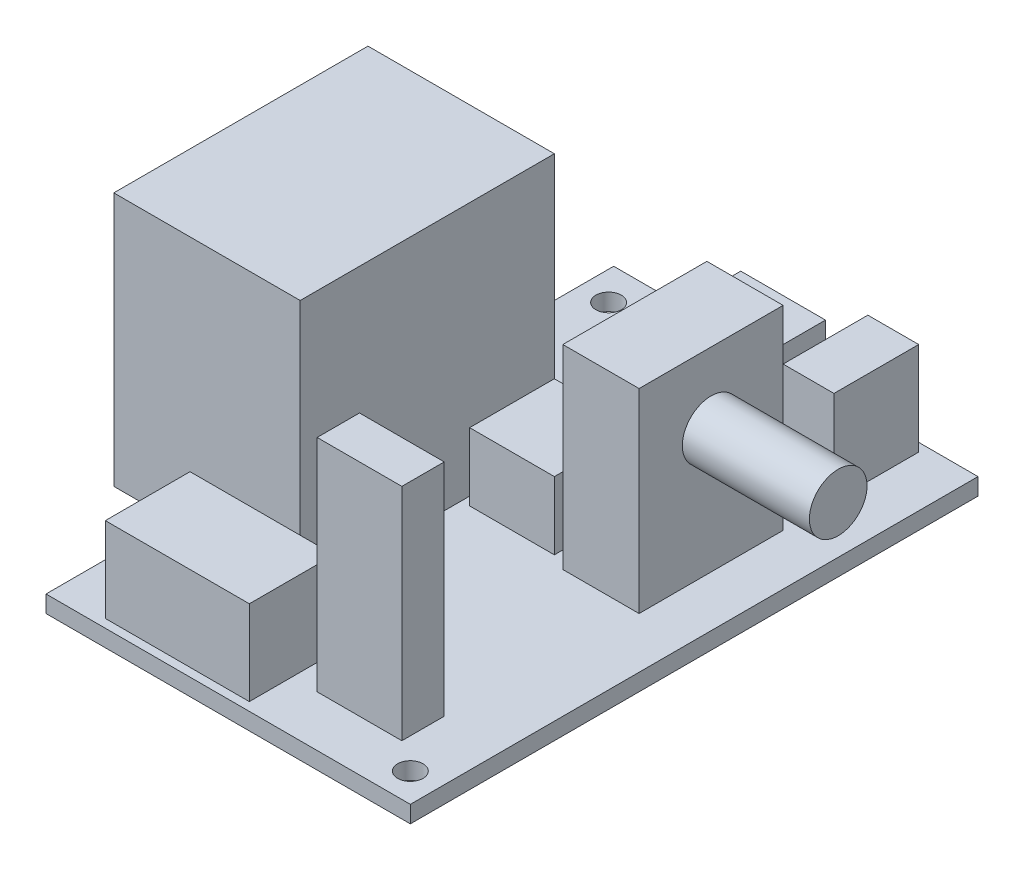
from build123d import *

# Parameters (mm, degrees)
SKETCH1_W              = 43
SKETCH1_H              = 112
SKETCH1_R              = 1.5
BOARD_DEPTH            = 2
SKETCH2_W              = 16
SKETCH2_H              = 40
SKETCH2_W_2            = 6
SKETCH2_H_2            = 10
F_7SEG_DEPTH           = 11
SKETCH3_W              = 10
SKETCH3_H              = 20
SKETCH3_H_2            = 10
IC_DEPTH               = 8
SKETCH5_W              = 9
SKETCH5_H              = 17
BIENTROA_DEPTH         = 23
SKETCH6_R              = 3.4
BIENTROB_DEPTH         = 15
SKETCH7_W              = 10
SKETCH7_H              = 5
IRF540_DEPTH           = 26
SKETCH8_W              = 17
SKETCH8_H              = 10
DOMINO_DEPTH           = 10
SKETCH9_W              = 22
SKETCH9_H              = 30
EXTRUDE_7805_DEPTH     = 30
SPLIT2_SURFACE_1_BACK  = 131.572
SPLIT2_SURFACE_1_DEPTH = 263.144
SPLIT2_SURFACE_2_BACK  = 131.572
SPLIT2_SURFACE_2_DEPTH = 263.144


with BuildPart() as part:
    # Sketch1 → Board (new body)
    with BuildSketch(Plane(origin=(0, 0, 0), x_dir=(1, 0, 0), z_dir=(0, 1, 0))):
        Rectangle(SKETCH1_W, SKETCH1_H)
        with Locations(Location((18.1, -52.6, 0), (0, 0, 270))):
            Circle(SKETCH1_R, mode=Mode.SUBTRACT)
        with Locations(Location((-16.5, 52, 0), (0, 0, 270))):
            Circle(SKETCH1_R, mode=Mode.SUBTRACT)
        with Locations(Location((-18.1, 7, 0), (0, 0, 270))):
            Circle(SKETCH1_R, mode=Mode.SUBTRACT)
    extrude(amount=BOARD_DEPTH)

    # Sketch2 → 7SEG (add)
    with BuildSketch(Plane(origin=(0, 2, 0), x_dir=(1, 0, 0), z_dir=(0, 1, 0))):
        with Locations((8.5, 31)):
            Rectangle(SKETCH2_W, SKETCH2_H)
        with Locations((12.5, 5)):
            Rectangle(SKETCH2_W_2, SKETCH2_H_2)
    extrude(amount=F_7SEG_DEPTH)

    # Sketch3 → IC (add)
    with BuildSketch(Plane(origin=(0, 2, 0), x_dir=(1, 0, 0), z_dir=(0, 1, 0))):
        with Locations((-6.5, 26)):
            Rectangle(SKETCH3_W, SKETCH3_H)
        with Locations((-0.5, 5)):
            Rectangle(SKETCH3_W, SKETCH3_H_2)
        with Locations((-0.5, -17)):
            Rectangle(SKETCH3_W, SKETCH3_H_2)
    extrude(amount=IC_DEPTH)

    # Sketch5 → BienTroA (add)
    with BuildSketch(Plane(origin=(0, 2, 0), x_dir=(1, 0, 0), z_dir=(0, 1, 0))):
        with Locations((11, -14.5)):
            Rectangle(SKETCH5_W, SKETCH5_H)
    extrude(amount=BIENTROA_DEPTH)

    # Sketch6 → BienTroB (add)
    with BuildSketch(Plane(origin=(15.5, 0, 0), x_dir=(0, 0, -1), z_dir=(1, 0, 0))):
        with Locations(Location((-14.5, 16.6, 0), (0, 0, 180))):
            Circle(SKETCH6_R)
    extrude(amount=BIENTROB_DEPTH)

    # Sketch7 → IRF540 (add)
    with BuildSketch(Plane(origin=(0, 2, 0), x_dir=(1, 0, 0), z_dir=(0, 1, 0))):
        with Locations((9.5, -47.5)):
            Rectangle(SKETCH7_W, SKETCH7_H)
    extrude(amount=IRF540_DEPTH)

    # Sketch8 → Domino (add)
    with BuildSketch(Plane(origin=(0, 2, 0), x_dir=(1, 0, 0), z_dir=(0, 1, 0))):
        with Locations((-7, -50)):
            Rectangle(SKETCH8_W, SKETCH8_H)
    extrude(amount=DOMINO_DEPTH)

    # Sketch9 → 7805 (add)
    with BuildSketch(Plane(origin=(0, 2, 0), x_dir=(1, 0, 0), z_dir=(0, 1, 0))):
        with Locations((-17.5, -26)):
            Rectangle(SKETCH9_W, SKETCH9_H)
    extrude(amount=EXTRUDE_7805_DEPTH)


with BuildPart() as body_2:
    # Split2: the piece behind the surface
    add(part.part)
    # Split2 surface: a surface, the sketch's curves swept straight by 263.144 mm
    with BuildLine(Plane(origin=(0, 2, 0), x_dir=(1, 0, 0), z_dir=(0, 1, 0)).offset(-SPLIT2_SURFACE_1_BACK), mode=Mode.PRIVATE) as split2_surface_1_path:
        Line((21.5, 11), (-21.5, 11))
    split2_surface_1 = Shell.extrude(split2_surface_1_path.wire(), (0 * SPLIT2_SURFACE_1_DEPTH, 1 * SPLIT2_SURFACE_1_DEPTH, 0 * SPLIT2_SURFACE_1_DEPTH))
    split(bisect_by=split2_surface_1, keep=Keep.BOTTOM)


with BuildPart() as part_1:
    add(part.part)

    # Split2: split by a surface, the side it looks to stays
    # Split2 surface: a surface, the sketch's curves swept straight by 263.144 mm
    with BuildLine(Plane(origin=(0, 2, 0), x_dir=(1, 0, 0), z_dir=(0, 1, 0)).offset(-SPLIT2_SURFACE_2_BACK), mode=Mode.PRIVATE) as split2_surface_2_path:
        Line((21.5, 11), (-21.5, 11))
    split2_surface_2 = Shell.extrude(split2_surface_2_path.wire(), (0 * SPLIT2_SURFACE_2_DEPTH, 1 * SPLIT2_SURFACE_2_DEPTH, 0 * SPLIT2_SURFACE_2_DEPTH))
    split(bisect_by=split2_surface_2, keep=Keep.TOP)


solid = part_1.part
